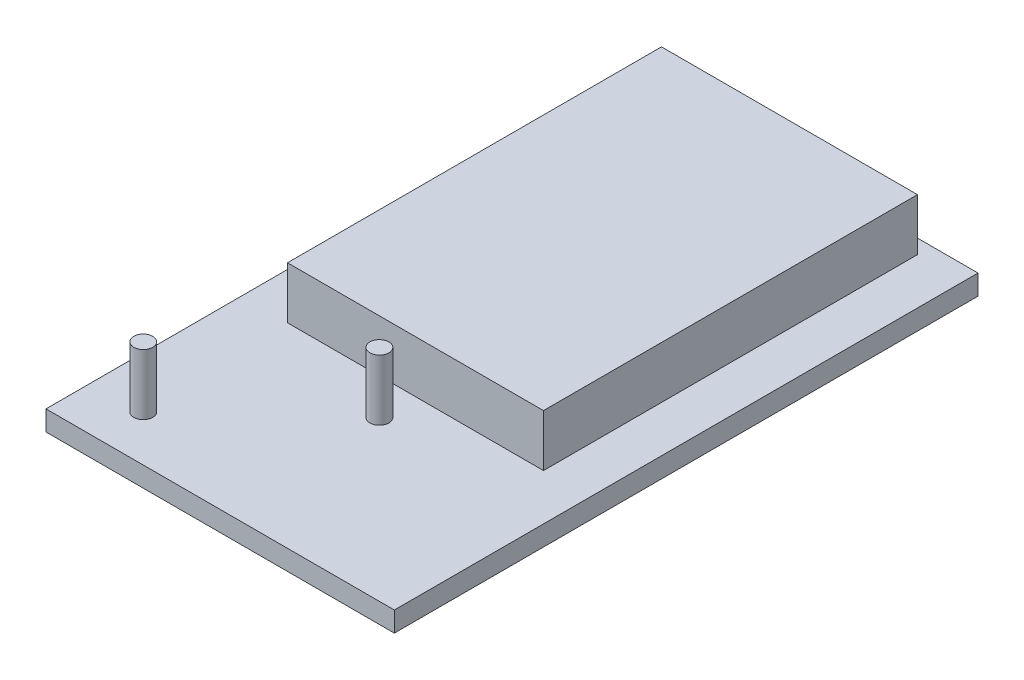
from build123d import *

# Parameters (mm, degrees)
SKETCH1_W           = 85.47
SKETCH1_H           = 143.2
BOSS_EXTRUDE1_DEPTH = 4.92
SKETCH2_W           = 62.81
SKETCH2_H           = 91.76
BOSS_EXTRUDE2_DEPTH = 12.75
SKETCH3_R           = 2.33
BOSS_EXTRUDE3_DEPTH = 14.9


with BuildPart() as part:
    # Sketch1 → Boss-Extrude1 (new body)
    with BuildSketch(Plane(origin=(0, 0, 0), x_dir=(1, 0, 0), z_dir=(0, 1, 0))):
        Rectangle(SKETCH1_W, SKETCH1_H)
    extrude(amount=BOSS_EXTRUDE1_DEPTH)

    # Sketch2 → Boss-Extrude2 (add)
    with BuildSketch(Plane(origin=(0, 4.92, 0), x_dir=(1, 0, 0), z_dir=(0, 1, 0))):
        with Locations((0, 22.2)):
            Rectangle(SKETCH2_W, SKETCH2_H)
    extrude(amount=BOSS_EXTRUDE2_DEPTH)

    # Sketch3 → Boss-Extrude3 (add)
    with BuildSketch(Plane(origin=(0, 4.92, 0), x_dir=(1, 0, 0), z_dir=(0, 1, 0))):
        with Locations((0, -32.53)):
            Circle(SKETCH3_R)
        with Locations((-30.156916038, -60.313935435)):
            Circle(SKETCH3_R)
    extrude(amount=BOSS_EXTRUDE3_DEPTH)


solid = part.part
